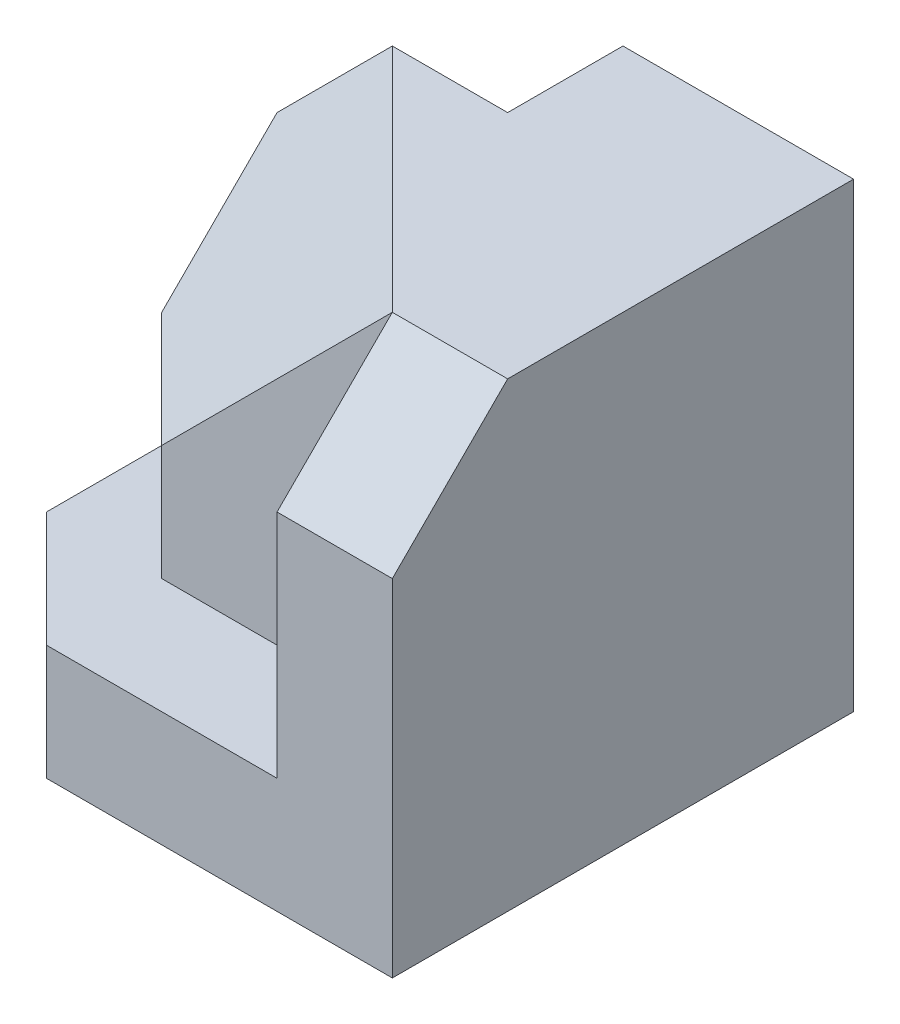
from build123d import *

# Parameters (mm, degrees)
BOSS_EXTRUDE2_DEPTH = 20
SKETCH3_W           = 5
SKETCH3_H           = 20
BOSS_EXTRUDE4_DEPTH = 5
CUT_EXTRUDE1_DEPTH  = 5
SKETCH5_W           = 5
SKETCH5_H           = 20
BOSS_EXTRUDE5_DEPTH = 5
CUT_EXTRUDE2_DEPTH  = 5
SKETCH7_W           = 5
SKETCH7_H           = 15
BOSS_EXTRUDE6_DEPTH = 5
BOSS_EXTRUDE7_DEPTH = 20
CUT_EXTRUDE3_DEPTH  = 20
BOSS_EXTRUDE8_DEPTH = 5
BOSS_EXTRUDE9_DEPTH = 5


with BuildPart() as part:
    # Sketch2 → Boss-Extrude2 (new body)
    with BuildSketch(Plane(origin=(0, 0, 0), x_dir=(1, 0, 0), z_dir=(0, 1, 0))):
        Polygon((0, 0), (10, 0), (10, -15), (5, -15), (-5, -5), (0, -5), align=None)
    extrude(amount=BOSS_EXTRUDE2_DEPTH)

    # Sketch3 → Boss-Extrude4 (add)
    with BuildSketch(Plane.XY.offset(15)):
        with Locations((7.5, 10)):
            Rectangle(SKETCH3_W, SKETCH3_H)
    extrude(amount=BOSS_EXTRUDE4_DEPTH)

    # Sketch4 → Cut-Extrude1 (cut)
    with BuildSketch(Plane.ZY.offset(-5)):
        Polygon((15, 20), (20, 15), (20, 20), align=None)
    extrude(amount=-CUT_EXTRUDE1_DEPTH, mode=Mode.SUBTRACT)

    # Sketch5 → Boss-Extrude5 (add)
    with BuildSketch(Plane.ZY):
        with Locations((2.5, 10)):
            Rectangle(SKETCH5_W, SKETCH5_H)
    extrude(amount=BOSS_EXTRUDE5_DEPTH)

    # Sketch6 → Cut-Extrude2 (cut)
    with BuildSketch(Plane(origin=(0, 0, 0), x_dir=(-1, 0, 0), z_dir=(0, 0, -1))):
        Polygon((0, 20), (5, 20), (5, 15), align=None)
    extrude(amount=-CUT_EXTRUDE2_DEPTH, mode=Mode.SUBTRACT)

    # Sketch7 → Boss-Extrude6 (add)
    with BuildSketch(Plane.ZY.offset(5)):
        with Locations((2.5, 7.5)):
            Rectangle(SKETCH7_W, SKETCH7_H)
    extrude(amount=BOSS_EXTRUDE6_DEPTH)

    # Sketch8 → Boss-Extrude7 (add)
    with BuildSketch(Plane(origin=(0, 0, 0), x_dir=(-1, 0, 0), z_dir=(0, -1, 0))):
        Polygon((10, -5), (5, -5), (-5, -15), (5, -15), (10, -10), align=None)
    extrude(amount=-BOSS_EXTRUDE7_DEPTH)

    # 3DSketch1 → Cut-Extrude3 (cut, along a direction that is not the sketch's normal)
    with BuildSketch(Plane(origin=(-5, 10, 15), x_dir=(0.7071067811865476, 0.7071067811865476, 0), z_dir=(-0.5773502691896257, 0.5773502691896257, 0.577350269189626))):
        Polygon((0, 0), (14.142135624, 0), (7.071067812, 12.247448714), (0, 12.247448714), (-3.535533906, 6.123724357), align=None)
    extrude(amount=CUT_EXTRUDE3_DEPTH, dir=(0, 1, 0), mode=Mode.SUBTRACT)

    # Sketch9 → Boss-Extrude8 (add)
    with BuildSketch(Plane(origin=(0, 0, 0), x_dir=(-1, 0, 0), z_dir=(0, -1, 0))):
        Polygon((5, -20), (10, -15), (10, -10), (5, -15), (-5, -15), (-5, -20), align=None)
    extrude(amount=-BOSS_EXTRUDE8_DEPTH)

    # Sketch10 → Boss-Extrude9 (add)
    with BuildSketch(Plane(origin=(0, 5, 0), x_dir=(1, 0, 0), z_dir=(0, 1, 0))):
        Polygon((0, -15), (5, -20), (5, -15), align=None)
    extrude(amount=BOSS_EXTRUDE9_DEPTH)


solid = part.part
